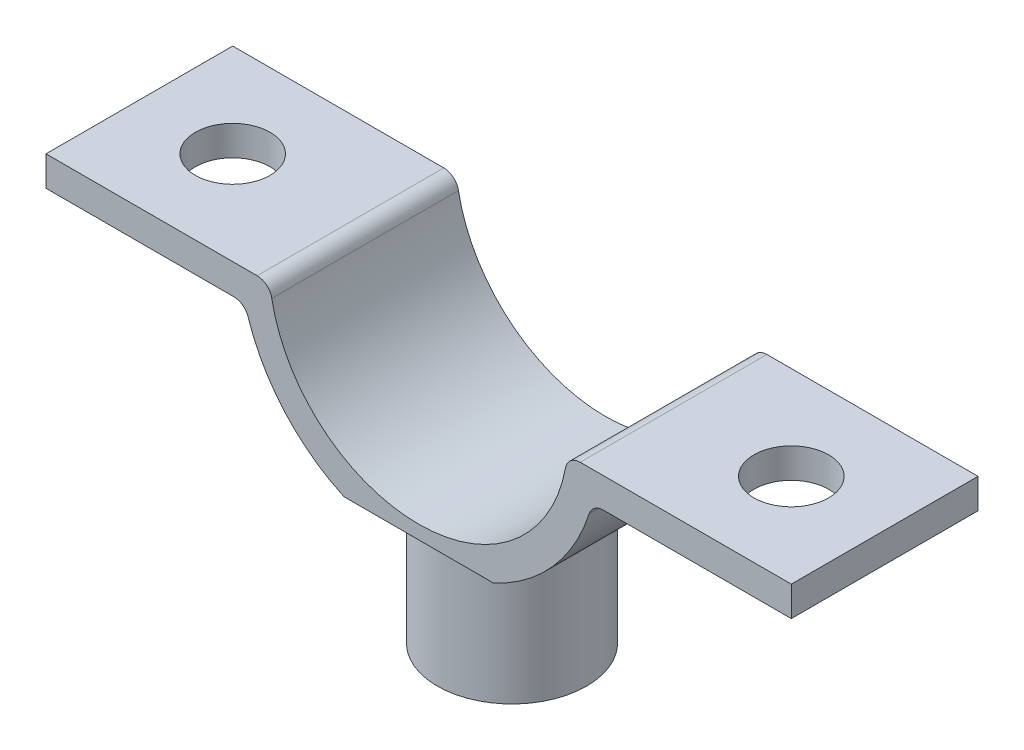
from build123d import *

# Parameters (mm, degrees)
BOSS_EXTRUDE1_DEPTH = 12.5
SKETCH4_OUTSIDE_W   = 62.868
SKETCH4_OUTSIDE_H   = 25.468
SKETCH4_OUTSIDE_R   = 5
CUT_EXTRUDE6_DEPTH  = 9.11
SKETCH5_R           = 3
CUT_EXTRUDE7_DEPTH  = 9.11
CUT_EXTRUDE8_REACH  = 21.017
SKETCH6_R           = 2.5


with BuildPart() as part:
    # Sketch1 → Boss-Extrude1 (new body)
    with BuildSketch(Plane.XY):
        with BuildLine():
            Line((-10.816653826, 19.01731952), (-19.949874371, 19.01731952))
            Line((-19.949874371, 19.01731952), (-24.949874371, 19.01731952))
            Line((-24.949874371, 19.01731952), (-24.949874371, 17.01731952))
            Line((-24.949874371, 17.01731952), (-19.949874371, 17.01731952))
            Line((-19.949874371, 17.01731952), (-12.369316877, 17.01731952))
            ThreePointArc((-12.369316877, 17.01731952), (-11.780968471, 16.82592706), (-11.417830963, 16.325011828))
            ThreePointArc((-11.417830963, 16.325011828), (-8.966906745, 12.042698311), (-5, 9.108607405))
            Line((-5, 9.108607405), (-5, 0))
            Line((-5, 0), (5, 0))
            Line((5, 0), (5, 9.108607405))
            ThreePointArc((5, 9.108607405), (8.966906745, 12.042698311), (11.417830963, 16.325011828))
            ThreePointArc((11.417830963, 16.325011828), (11.780968471, 16.82592706), (12.369316877, 17.01731952))
            Line((12.369316877, 17.01731952), (19.949874371, 17.01731952))
            Line((19.949874371, 17.01731952), (24.949874371, 17.01731952))
            Line((24.949874371, 17.01731952), (24.949874371, 19.01731952))
            Line((24.949874371, 19.01731952), (19.949874371, 19.01731952))
            Line((19.949874371, 19.01731952), (10.816653826, 19.01731952))
            ThreePointArc((10.816653826, 19.01731952), (10.177051677, 18.786025635), (9.83332166, 18.199137702))
            ThreePointArc((9.83332166, 18.199137702), (0, 10.01731952), (-9.83332166, 18.199137702))
            ThreePointArc((-9.83332166, 18.199137702), (-10.177051677, 18.786025635), (-10.816653826, 19.01731952))
        make_face()
    extrude(amount=BOSS_EXTRUDE1_DEPTH)

    # Sketch4 outside → Cut-Extrude6 (cut)
    with BuildSketch(Plane.XZ):
        with Locations((0, 6.25)):
            Rectangle(SKETCH4_OUTSIDE_W, SKETCH4_OUTSIDE_H)
        with Locations((0, 6.25)):
            Circle(SKETCH4_OUTSIDE_R, mode=Mode.SUBTRACT)
    extrude(amount=-CUT_EXTRUDE6_DEPTH, mode=Mode.SUBTRACT)

    # Sketch5 → Cut-Extrude7 (cut)
    with BuildSketch(Plane.XZ):
        with Locations((0, 6.25)):
            Circle(SKETCH5_R)
    extrude(amount=-CUT_EXTRUDE7_DEPTH, mode=Mode.SUBTRACT)

    # Sketch6 → Cut-Extrude8 (cut, up to next)
    with BuildSketch(Plane(origin=(0, 19.01731952, 0), x_dir=(1, 0, 0), z_dir=(0, 1, 0)), mode=Mode.PRIVATE) as cut_extrude8_sk1:
        with Locations((-18.699874371, -6.25)):
            Circle(SKETCH6_R)
    cut_extrude8_tool1 = extrude(cut_extrude8_sk1.sketch, amount=-CUT_EXTRUDE8_REACH, mode=Mode.PRIVATE) & part.part
    add(cut_extrude8_tool1.solids().sort_by_distance((-18.699874, 19.01732, 6.25))[0], mode=Mode.SUBTRACT)
    # Sketch6 → Cut-Extrude8 (cut, up to next)
    with BuildSketch(Plane(origin=(0, 19.01731952, 0), x_dir=(1, 0, 0), z_dir=(0, 1, 0)), mode=Mode.PRIVATE) as cut_extrude8_sk2:
        with Locations((18.699874371, -6.25)):
            Circle(SKETCH6_R)
    cut_extrude8_tool2 = extrude(cut_extrude8_sk2.sketch, amount=-CUT_EXTRUDE8_REACH, mode=Mode.PRIVATE) & part.part
    add(cut_extrude8_tool2.solids().sort_by_distance((18.699874, 19.01732, 6.25))[0], mode=Mode.SUBTRACT)


solid = part.part
